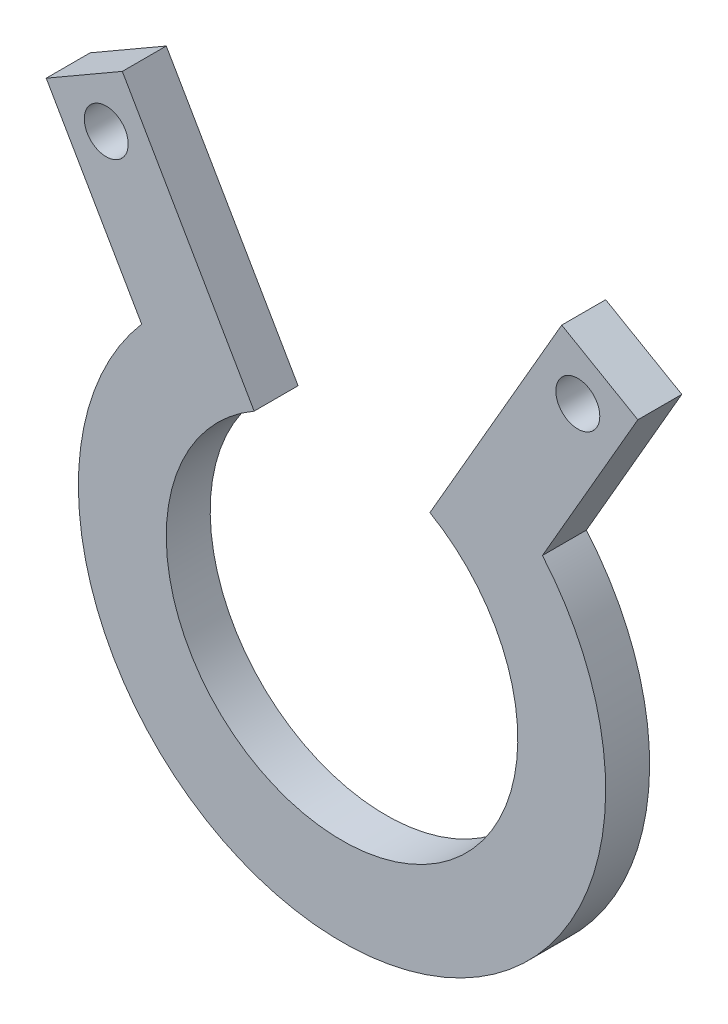
from build123d import *

# Parameters (mm, degrees)
SKETCH2_R           = 19.05
SKETCH2_R_2         = 15.875
SKETCH2_R_3         = 12.7
BOSS_EXTRUDE1_DEPTH = 3.175
SKETCH3_R           = 1.5875
BOSS_EXTRUDE2_DEPTH = 3.175
CUT_EXTRUDE1_DEPTH  = 3.175


with BuildPart() as part:
    # Sketch2 → Boss-Extrude1 (new body)
    with BuildSketch(Plane.XY):
        Circle(SKETCH2_R)
        Circle(SKETCH2_R_2, mode=Mode.SUBTRACT)
        Circle(SKETCH2_R_2)
        Circle(SKETCH2_R_3, mode=Mode.SUBTRACT)
    extrude(amount=BOSS_EXTRUDE1_DEPTH)

    # Sketch3 → Boss-Extrude2 (add)
    with BuildSketch(Plane.XY.offset(3.175)):
        with BuildLine():
            ThreePointArc((-14.479517435, 12.379259867), (-12.17763419, 14.649495743), (-9.525, 16.497783942))
            Line((-9.525, 16.497783942), (-15.875, 27.49630657))
            Line((-15.875, 27.49630657), (-21.374261314, 24.32130657))
            Line((-21.374261314, 24.32130657), (-15.024261314, 13.322783942))
            Line((-15.024261314, 13.322783942), (-14.479517435, 12.379259867))
        make_face()
        with Locations((-17.037130657, 23.159175913)):
            Circle(SKETCH3_R, mode=Mode.SUBTRACT)
        with BuildLine():
            Line((15.875, 27.49630657), (9.525, 16.497783942))
            ThreePointArc((9.525, 16.497783942), (12.17763419, 14.649495743), (14.479517435, 12.379259867))
            Line((14.479517435, 12.379259867), (15.024261314, 13.322783942))
            Line((15.024261314, 13.322783942), (21.374261314, 24.32130657))
            Line((21.374261314, 24.32130657), (15.875, 27.49630657))
        make_face()
        with Locations((17.037130657, 23.159175913)):
            Circle(SKETCH3_R, mode=Mode.SUBTRACT)
    extrude(amount=-BOSS_EXTRUDE2_DEPTH)

    # Sketch5 → Cut-Extrude1 (cut)
    with BuildSketch(Plane.XY.offset(3.175)):
        with BuildLine():
            Line((-9.525, 16.497783942), (0, 0))
            Line((0, 0), (9.525, 16.497783942))
            ThreePointArc((9.525, 16.497783942), (0, 19.05), (-9.525, 16.497783942))
        make_face()
    extrude(amount=-CUT_EXTRUDE1_DEPTH, mode=Mode.SUBTRACT)


solid = part.part
